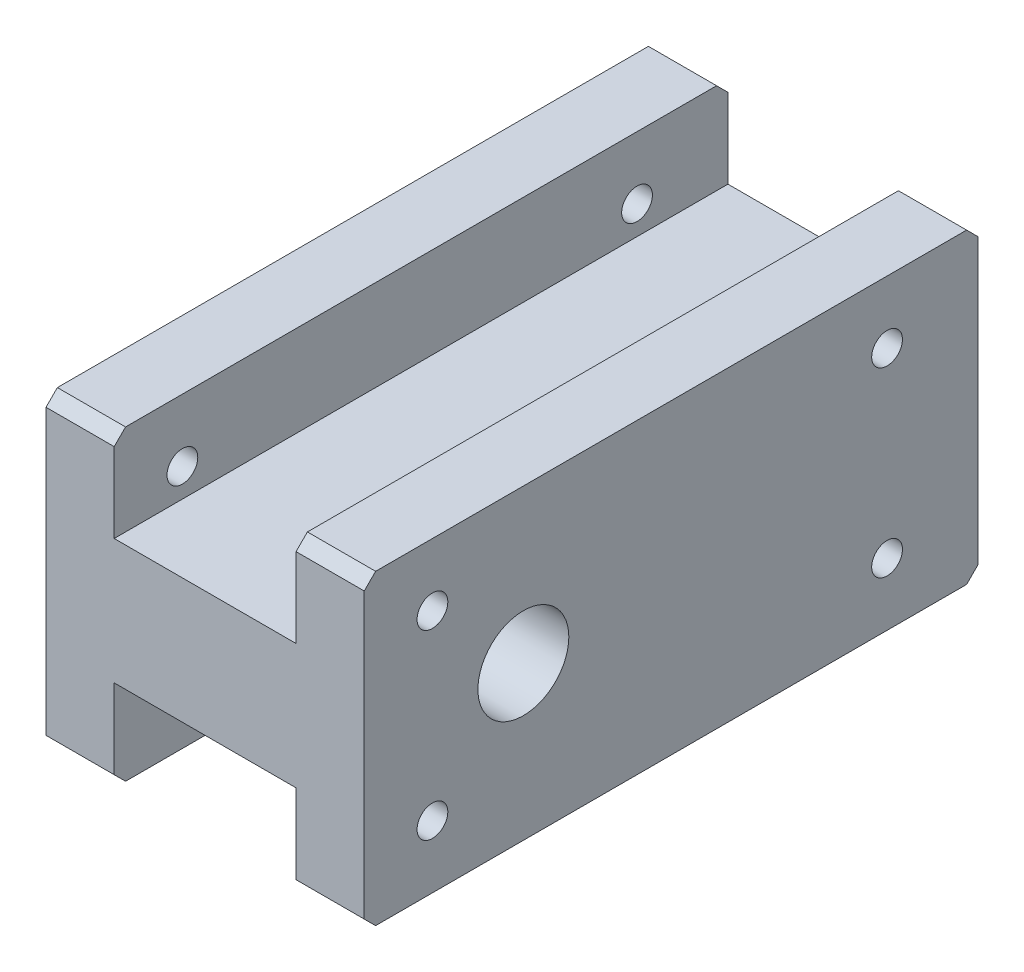
from build123d import *

# Parameters (mm, degrees)
SKETCH1_W             = 54
SKETCH1_H             = 27
SKETCH1_R             = 4
BOSS_EXTRUDE1_DEPTH   = 28
F_6_32_TAPPED_HOLE1_D = 2.7051
SKETCH4_W             = 16
SKETCH4_H             = 8
CUT_EXTRUDE1_DEPTH    = 55
CHAMFER1_SIZE         = 1


with BuildPart() as part:
    # Sketch1 → Boss-Extrude1 (new body)
    with BuildSketch(Plane(origin=(0, 0, 0), x_dir=(0, 0, -1), z_dir=(1, 0, 0))):
        with Locations((13, 0)):
            Rectangle(SKETCH1_W, SKETCH1_H)
        Circle(SKETCH1_R, mode=Mode.SUBTRACT)
    extrude(amount=-BOSS_EXTRUDE1_DEPTH)

    # #6-32 Tapped Hole1 (through all)
    with Locations(Plane(origin=(0, 0, 0), x_dir=(0, 0, -1), z_dir=(1, 0, 0))):
        with Locations((-8, 8), (-8, -8), (32, -8), (32, 8)):
            Hole(F_6_32_TAPPED_HOLE1_D / 2)

    # Sketch4 → Cut-Extrude1 (cut, through all)
    with BuildSketch(Plane.XY.offset(14)):
        with Locations((-14, 9.5)):
            Rectangle(SKETCH4_W, SKETCH4_H)
        with Locations((-14, -9.5)):
            Rectangle(SKETCH4_W, SKETCH4_H)
    extrude(amount=-CUT_EXTRUDE1_DEPTH, mode=Mode.SUBTRACT)

    # Chamfer1
    chamfer1_edges = [part.edges().sort_by_distance(p)[0] for p in [
        (-3, 13.5, -40),
        (-3, 13.5, 14),
        (-3, -13.5, 14),
        (-3, -13.5, -40),
        (-25, 13.5, 14),
        (-25, 13.5, -40),
        (-25, -13.5, -40),
        (-25, -13.5, 14),
    ]]
    chamfer(chamfer1_edges, length=CHAMFER1_SIZE)


solid = part.part
